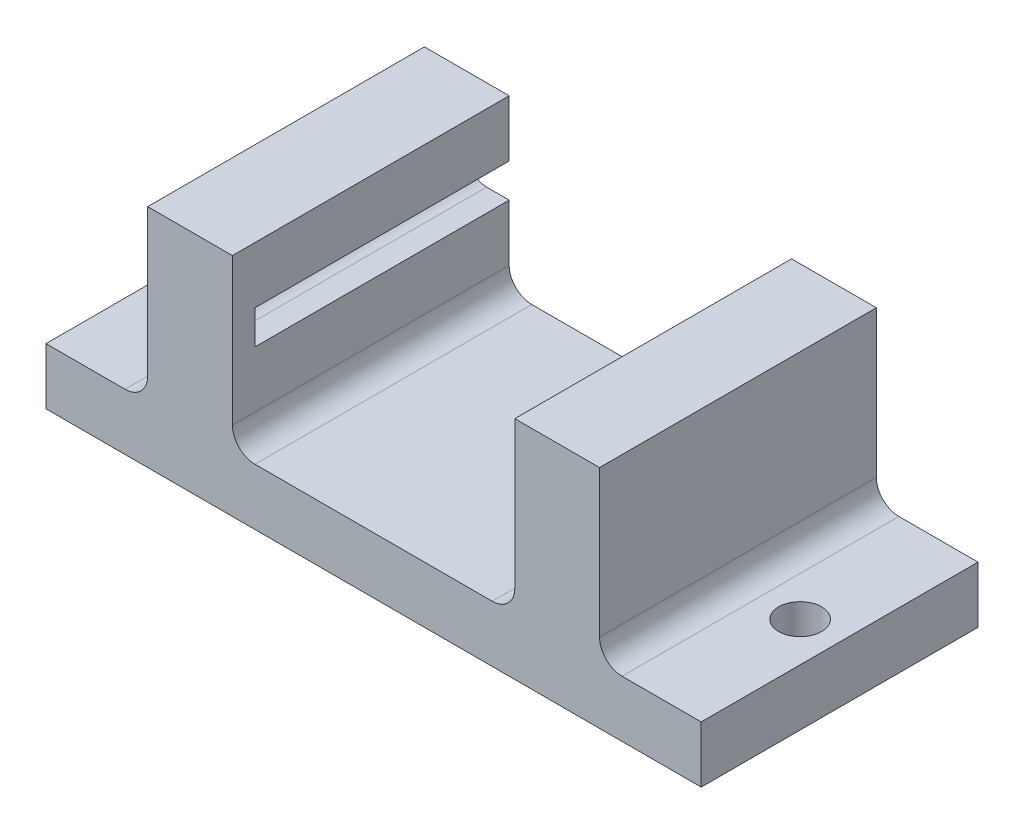
from build123d import *

# Parameters (mm, degrees)
BASE_DEPTH           = 28.575
BACK_PLATE_DEPTH     = 2.54
SKETCH4_R            = 2.413
MOUNTING_HOLES_DEPTH = 7.35


with BuildPart() as part:
    # Sketch2 → Base (new body)
    with BuildSketch(Plane.XY):
        with BuildLine():
            Line((13.335, -19.05), (0, -19.05))
            Line((0, -19.05), (0, -25.4))
            Line((0, -25.4), (36.83, -25.4))
            Line((36.83, -25.4), (36.83, -19.05))
            Line((36.83, -19.05), (27.94, -19.05))
            ThreePointArc((27.94, -19.05), (26.143948776, -18.306051224), (25.4, -16.51))
            Line((25.4, -16.51), (25.4, 0))
            Line((25.4, 0), (15.875, 0))
            Line((15.875, 0), (15.875, -6.35))
            Line((15.875, -6.35), (18.415, -6.35))
            ThreePointArc((18.415, -6.35), (20.32, -8.255), (18.415, -10.16))
            Line((18.415, -10.16), (15.875, -10.16))
            Line((15.875, -10.16), (15.875, -16.51))
            ThreePointArc((15.875, -16.51), (15.131051224, -18.306051224), (13.335, -19.05))
        make_face()
    base = extrude(amount=BASE_DEPTH)

    # Sketch5 → Back Plate (add)
    with BuildSketch(Plane.XY.offset(28.575)):
        with BuildLine():
            Line((0, -25.4), (36.83, -25.4))
            Line((36.83, -25.4), (36.83, -19.05))
            Line((36.83, -19.05), (27.94, -19.05))
            ThreePointArc((27.94, -19.05), (26.143948776, -18.306051224), (25.4, -16.51))
            Line((25.4, -16.51), (25.4, 0))
            Line((25.4, 0), (15.875, 0))
            Line((15.875, 0), (15.875, -6.35))
            Line((15.875, -6.35), (15.875, -10.16))
            Line((15.875, -10.16), (15.875, -16.51))
            ThreePointArc((15.875, -16.51), (15.131051224, -18.306051224), (13.335, -19.05))
            Line((13.335, -19.05), (0, -19.05))
            Line((0, -19.05), (0, -25.4))
        make_face()
    back_plate = extrude(amount=BACK_PLATE_DEPTH)

    # Sketch4 → Mounting Holes (cut, through all)
    with BuildSketch(Plane(origin=(0, -19.05, 0), x_dir=(1, 0, 0), z_dir=(0, 1, 0))):
        with Locations((32.385, -15.5575)):
            Circle(SKETCH4_R)
    mounting_holes = extrude(amount=-MOUNTING_HOLES_DEPTH, mode=Mode.SUBTRACT)

    # Mirror 2: Base, Back Plate, Mounting Holes across plane
    add(base.mirror(Plane(origin=(0, 0, 0), x_dir=(0, 0, 1), z_dir=(1, 0, 0))))
    add(back_plate.mirror(Plane(origin=(0, 0, 0), x_dir=(0, 0, 1), z_dir=(1, 0, 0))))
    add(mounting_holes.mirror(Plane(origin=(0, 0, 0), x_dir=(0, 0, 1), z_dir=(1, 0, 0))), mode=Mode.SUBTRACT)


solid = part.part
